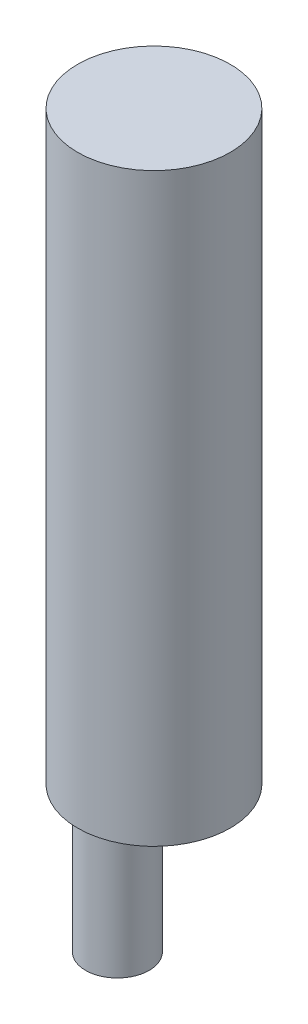
from build123d import *

# Parameters (mm, degrees)
SKETCH1_R           = 9
BOSS_EXTRUDE1_DEPTH = 34.5
SKETCH2_R           = 3.75
BOSS_EXTRUDE2_DEPTH = 15


with BuildPart() as part:
    # Sketch1 → Boss-Extrude1 (new body, symmetric)
    with BuildSketch(Plane(origin=(0, 0, 0), x_dir=(1, 0, 0), z_dir=(0, 1, 0))):
        Circle(SKETCH1_R)
    extrude(amount=BOSS_EXTRUDE1_DEPTH, both=True)

    # Sketch2 → Boss-Extrude2 (add)
    with BuildSketch(Plane.XZ.offset(34.5)):
        with Locations((0, 4.31062048)):
            Circle(SKETCH2_R)
    extrude(amount=BOSS_EXTRUDE2_DEPTH)


solid = part.part
